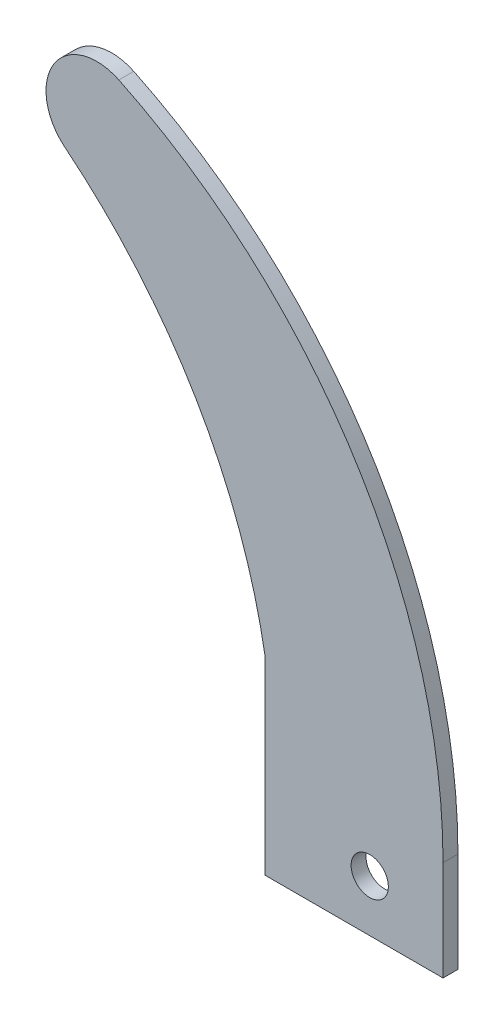
from build123d import *

# Parameters (mm, degrees)
SKETCH_1_R      = 2.5
EXTRUDE_1_DEPTH = 2


with BuildPart() as part:
    # Эскиз1 → Бобышка-Вытянуть1 (new body)
    with BuildSketch(Plane.XY):
        with BuildLine():
            Line((-14.033668667, -6.927741673), (9.836212535, -6.927741673))
            Line((9.836212535, -6.927741673), (9.836212535, 6.468384532))
            ThreePointArc((9.836212535, 6.468384532), (-1.939735679, 47.334627745), (-33.656179922, 75.668175974))
            ThreePointArc((-33.656179922, 75.668175974), (-42.372566631, 73.171176021), (-40.898194288, 64.224856542))
            ThreePointArc((-40.898194288, 64.224856542), (-23.309833652, 43.806018062), (-14.033668667, 18.503208773))
            Line((-14.033668667, 18.503208773), (-14.033668667, -6.927741673))
        make_face()
        Circle(SKETCH_1_R, mode=Mode.SUBTRACT)
    extrude(amount=EXTRUDE_1_DEPTH)


solid = part.part
